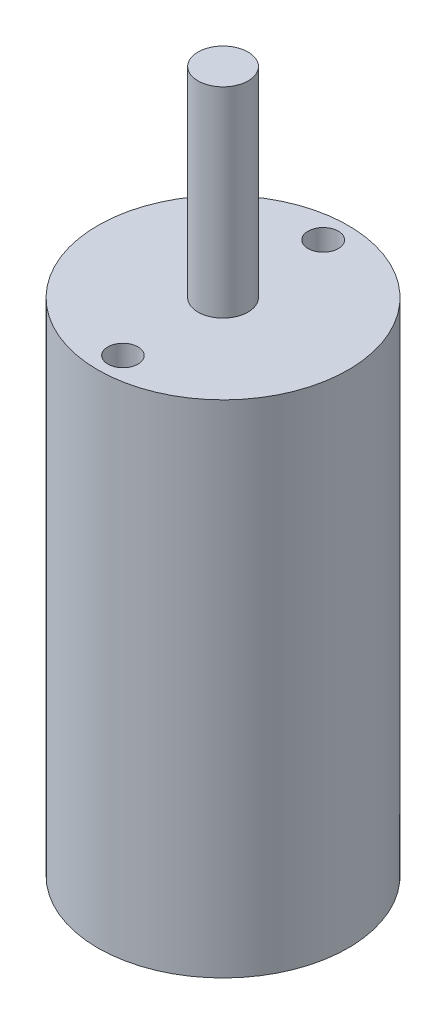
from build123d import *

# Parameters (mm, degrees)
SKETCH_1_R          = 12.5
EXTRUDE_1_DEPTH     = 50
SKETCH_2_R          = 1.5
SKETCH_2_R_2        = 1.512365131
CUT_EXTRUDE_1_DEPTH = 10
SKETCH_3_R          = 2.5
EXTRUDE_2_DEPTH     = 20


with BuildPart() as part:
    # 草图1 → 凸台-拉伸1 (new body)
    with BuildSketch(Plane(origin=(0, 0, 0), x_dir=(1, 0, 0), z_dir=(0, 1, 0))):
        Circle(SKETCH_1_R)
    extrude(amount=EXTRUDE_1_DEPTH)

    # 草图2 → 切除-拉伸1 (cut)
    with BuildSketch(Plane(origin=(0, 50, 0), x_dir=(1, 0, 0), z_dir=(0, 1, 0))):
        with Locations((0, -10)):
            Circle(SKETCH_2_R)
        with Locations((0, 10)):
            Circle(SKETCH_2_R_2)
    extrude(amount=-CUT_EXTRUDE_1_DEPTH, mode=Mode.SUBTRACT)

    # 草图3 → 凸台-拉伸2 (add)
    with BuildSketch(Plane(origin=(0, 50, 0), x_dir=(1, 0, 0), z_dir=(0, 1, 0))):
        Circle(SKETCH_3_R)
    extrude(amount=EXTRUDE_2_DEPTH)


solid = part.part
